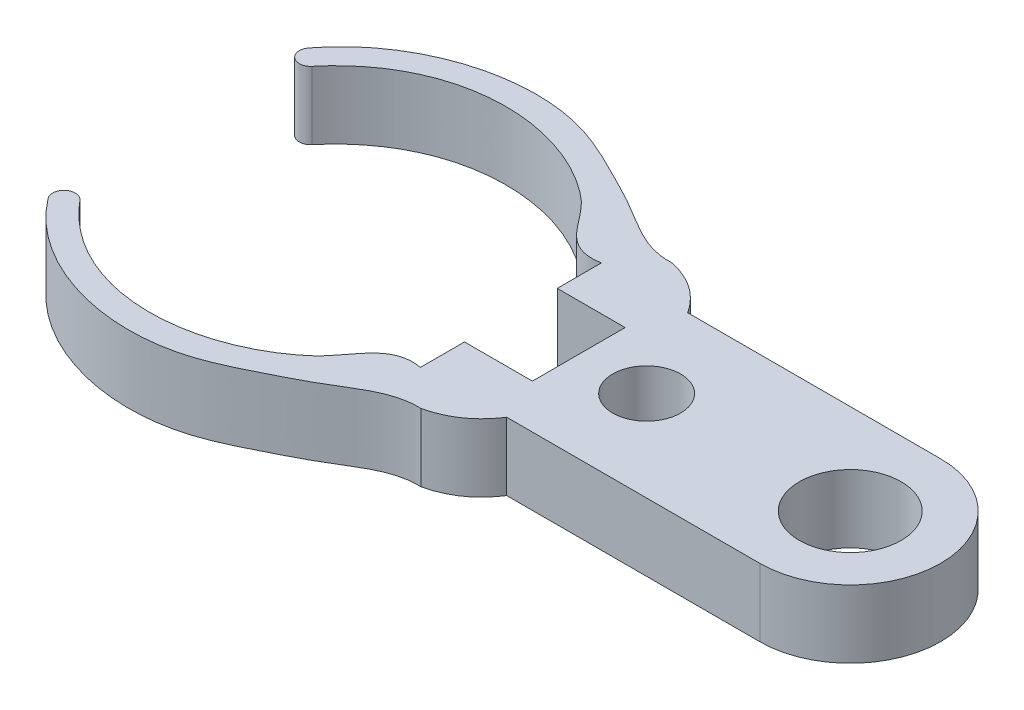
from build123d import *

# Parameters (mm, degrees)
SKETCH1_R           = 1.5
BOSS_EXTRUDE1_DEPTH = 3


with BuildPart() as part:
    # Sketch1 → Boss-Extrude1 (new body)
    with BuildSketch(Plane(origin=(0, 0, 0), x_dir=(1, 0, 0), z_dir=(0, 1, 0))):
        with BuildLine():
            Line((0, 1.95), (0, 0))
            Line((0, 0), (1.462394889, 0))
            Line((1.462394889, 0), (3.812496302, 0))
            Line((3.812496302, 0), (15, 0))
            Line((15, 0), (15, 1.75))
            ThreePointArc((15, 1.75), (12.75, 4), (15, 6.25))
            Line((15, 6.25), (15, 8))
            Line((15, 8), (3.812496302, 8))
            Line((3.812496302, 8), (0, 8))
            Line((0, 8), (0, 6.05))
            Line((0, 6.05), (3, 6.05))
            Line((3, 6.05), (3, 1.95))
            Line((3, 1.95), (0, 1.95))
        make_face()
        with Locations((6, 4)):
            Circle(SKETCH1_R, mode=Mode.SUBTRACT)
        with BuildLine():
            Line((1.462394889, 0), (0, 0))
            add(Edge.make_bspline(
                [(0, 0), (-1.444972113, 0.268364939), (-1.989778669, -1.274793611), (-5.99641862, -4.532476754), (-11.043579326, -4.596412752), (-13.923421089, -1.125163293)],
                knots=[0, 0, 0, 0, 0.216898357, 0.270831116, 1, 1, 1, 1], degree=3))
            ThreePointArc((-13.923421089, -1.125163293), (-14.628689505, -1.074207804), (-14.679644993, -1.77947622))
            add(Edge.make_bspline(
                [(-14.679644993, -1.77947622), (-12.628894453, -4.474080979), (-7.714296312, -5.95140451), (-3.34534031, -3.74006244), (-1.005631641, -2.560185408), (0.394595325, -1.501153093), (1.579778317, -1.560661502)],
                knots=[0, 0, 0, 0, 0.557352672, 0.711946673, 0.815566185, 1, 1, 1, 1], degree=3))
            Line((1.579778317, -1.560661502), (1.462394889, 0))
        make_face()
        with BuildLine():
            Line((3.812496302, 0), (1.462394889, 0))
            Line((1.462394889, 0), (1.579778317, -1.560661502))
            add(Edge.make_bspline(
                [(1.579778317, -1.560661502), (3.016371883, -1.23196193), (3.812496302, 0)],
                knots=[0, 0, 0, 1, 1, 1], degree=2))
        make_face()
        with BuildLine():
            Line((15, 1.75), (15, 0))
            ThreePointArc((15, 0), (19, 4), (15, 8))
            Line((15, 8), (15, 6.25))
            ThreePointArc((15, 6.25), (16.590990258, 5.590990258), (17.25, 4))
            ThreePointArc((17.25, 4), (16.590990258, 2.409009742), (15, 1.75))
        make_face()
        with BuildLine():
            add(Edge.make_bspline(
                [(0, 8), (-1.444972113, 7.731635061), (-1.989778669, 9.274793611), (-5.99641862, 12.532476754), (-11.043579326, 12.596412752), (-13.923421089, 9.125163293)],
                knots=[0, 0, 0, 0, 0.216898357, 0.270831116, 1, 1, 1, 1], degree=3))
            Line((0, 8), (3.812496302, 8))
            add(Edge.make_bspline(
                [(1.579778317, 9.560661502), (3.016371883, 9.23196193), (3.812496302, 8)],
                knots=[0, 0, 0, 1, 1, 1], degree=2))
            add(Edge.make_bspline(
                [(-14.679644993, 9.77947622), (-12.628894453, 12.474080979), (-7.714296312, 13.95140451), (-3.34534031, 11.74006244), (-1.005631641, 10.560185408), (0.394595325, 9.501153093), (1.579778317, 9.560661502)],
                knots=[0, 0, 0, 0, 0.557352672, 0.711946673, 0.815566185, 1, 1, 1, 1], degree=3))
            Line((-14.679644993, 9.77947622), (-13.923421089, 9.125163293))
        make_face()
        with BuildLine():
            ThreePointArc((-14.679644993, 9.77947622), (-14.628689505, 9.074207804), (-13.923421089, 9.125163293))
            Line((-13.923421089, 9.125163293), (-14.679644993, 9.77947622))
        make_face()
    extrude(amount=BOSS_EXTRUDE1_DEPTH)


solid = part.part
